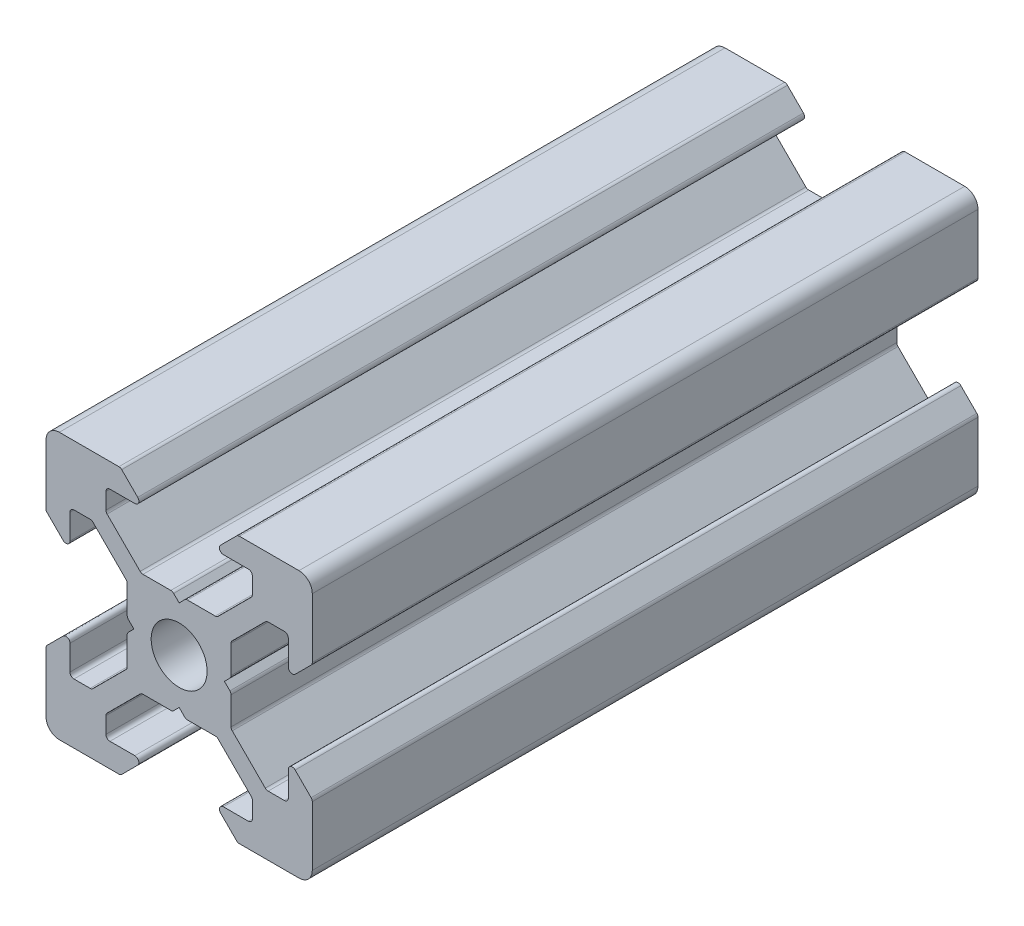
from build123d import *

# Parameters (mm, degrees)
SKETCH_1_R      = 2.1
EXTRUDE_1_DEPTH = 50
FILLET_1_R      = 1
FILLET_2_R      = 0.3


with BuildPart() as part:
    # Эскиз1 → Бобышка-Вытянуть1 (new body)
    with BuildSketch(Plane.XY):
        Polygon((-10, 10), (-4.4, 10), (-2.6, 8.2), (-5.499339828, 8.2), (-5.499339828, 6.56), (-2.84, 3.900660172), (-0.5, 3.900660172), (0, 3.400660172), (0.5, 3.900660172), (2.84, 3.900660172), (5.499339828, 6.56), (5.499339828, 8.2), (2.6, 8.2), (4.4, 10), (10, 10), (10, 4.4), (8.2, 2.6), (8.2, 5.499339828), (6.56, 5.499339828), (3.900660172, 2.84), (3.900660172, 0.5), (3.400660172, 0), (3.900660172, -0.5), (3.900660172, -2.84), (6.56, -5.499339828), (8.2, -5.499339828), (8.2, -2.6), (10, -4.4), (10, -10), (4.4, -10), (2.6, -8.2), (5.499339828, -8.2), (5.499339828, -6.56), (2.84, -3.900660172), (0.5, -3.900660172), (0, -3.400660172), (-0.5, -3.900660172), (-2.84, -3.900660172), (-5.499339828, -6.56), (-5.499339828, -8.2), (-2.6, -8.2), (-4.4, -10), (-10, -10), (-10, -4.4), (-8.2, -2.6), (-8.2, -5.499339828), (-6.56, -5.499339828), (-3.900660172, -2.84), (-3.900660172, -0.5), (-3.400660172, 0), (-3.900660172, 0.5), (-3.900660172, 2.84), (-6.56, 5.499339828), (-8.2, 5.499339828), (-8.2, 2.6), (-10, 4.4), align=None)
        Circle(SKETCH_1_R, mode=Mode.SUBTRACT)
    extrude(amount=EXTRUDE_1_DEPTH)

    # Скругление1
    fillet_1_edges = [part.edges().sort_by_distance(p)[0] for p in [
        (-10, 10, 25),
        (10, 10, 25),
        (10, -10, 25),
        (-10, -10, 25),
    ]]
    fillet(fillet_1_edges, radius=FILLET_1_R)

    # Скругление2
    fillet_2_edges = [part.edges().sort_by_distance(p)[0] for p in [
        (-4.4, 10, 25),
        (-2.6, 8.2, 25),
        (-5.499339828, 8.2, 25),
        (-5.499339828, 6.56, 25),
        (-2.84, 3.900660172, 25),
        (-0.5, 3.900660172, 25),
        (0.5, 3.900660172, 25),
        (2.84, 3.900660172, 25),
        (5.499339828, 6.56, 25),
        (5.499339828, 8.2, 25),
        (2.6, 8.2, 25),
        (4.4, 10, 25),
        (10, 4.4, 25),
        (8.2, 2.6, 25),
        (8.2, 5.499339828, 25),
        (6.56, 5.499339828, 25),
        (3.900660172, 2.84, 25),
        (3.900660172, 0.5, 25),
        (3.900660172, -0.5, 25),
        (3.900660172, -2.84, 25),
        (6.56, -5.499339828, 25),
        (8.2, -5.499339828, 25),
        (8.2, -2.6, 25),
        (10, -4.4, 25),
        (4.4, -10, 25),
        (2.6, -8.2, 25),
        (5.499339828, -8.2, 25),
        (5.499339828, -6.56, 25),
        (2.84, -3.900660172, 25),
        (0.5, -3.900660172, 25),
        (-0.5, -3.900660172, 25),
        (-2.84, -3.900660172, 25),
        (-5.499339828, -6.56, 25),
        (-5.499339828, -8.2, 25),
        (-2.6, -8.2, 25),
        (-4.4, -10, 25),
        (-10, -4.4, 25),
        (-8.2, -2.6, 25),
        (-8.2, -5.499339828, 25),
        (-6.56, -5.499339828, 25),
        (-3.900660172, -2.84, 25),
        (-3.900660172, -0.5, 25),
        (-3.900660172, 0.5, 25),
        (-3.900660172, 2.84, 25),
        (-6.56, 5.499339828, 25),
        (-8.2, 5.499339828, 25),
        (-8.2, 2.6, 25),
    ]]
    fillet(fillet_2_edges, radius=FILLET_2_R)


solid = part.part
